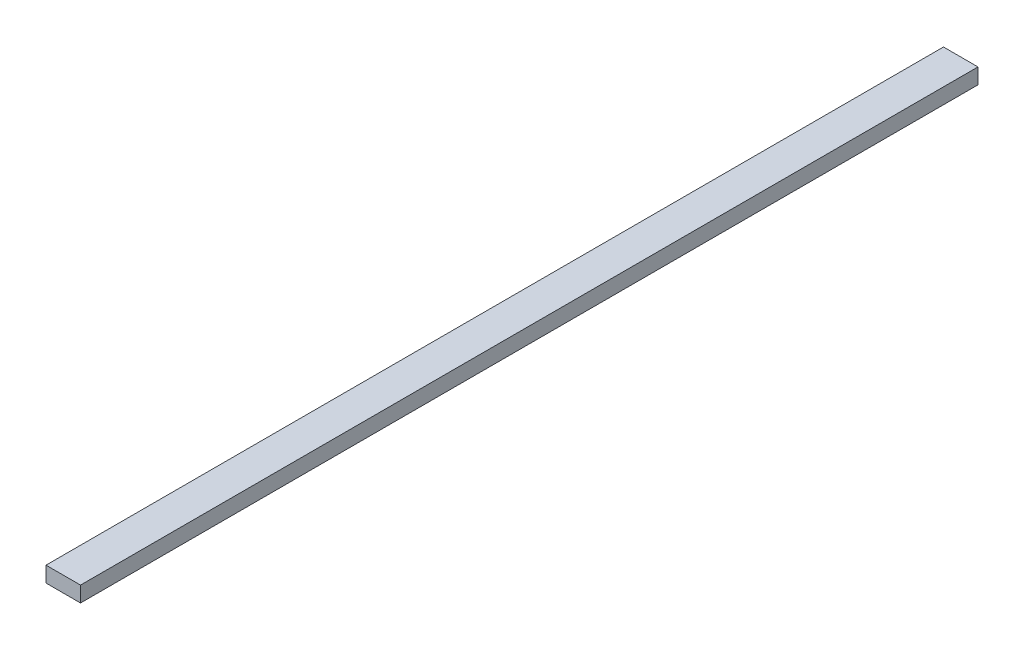
from build123d import *

# Parameters (mm, degrees)
CROQUIS1_W              = 4
CROQUIS1_H              = 1.8
SALIENTE_EXTRUIR1_DEPTH = 104


with BuildPart() as part:
    # Croquis1 → Saliente-Extruir1 (new body)
    with BuildSketch(Plane.XY):
        with Locations((-8.081967213, 0.895081967)):
            Rectangle(CROQUIS1_W, CROQUIS1_H)
    extrude(amount=SALIENTE_EXTRUIR1_DEPTH)


solid = part.part
